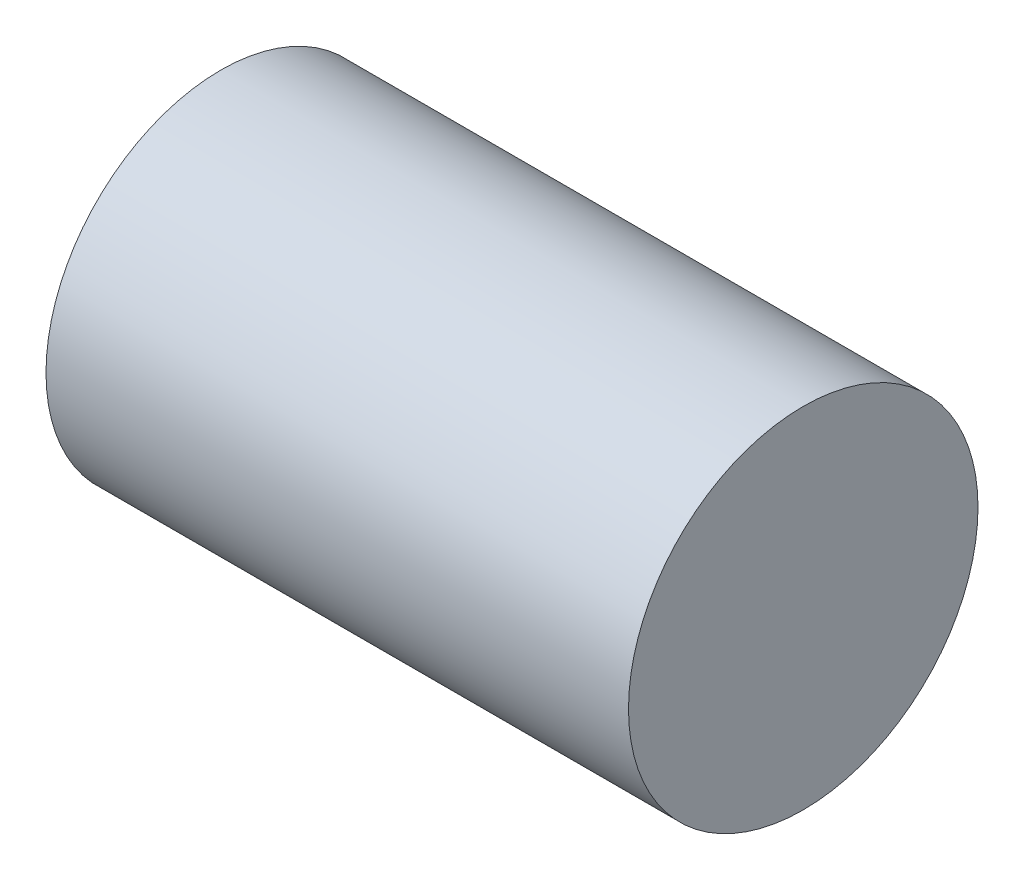
from build123d import *


with BuildPart() as part:
    # Sketch1 → Base-Revolve (revolve)
    with BuildSketch(Plane.XY):
        Polygon((0, 4), (0, 6), (20, 6), (20, 0), (17, 0), (17, 4), align=None)
    revolve(axis=Axis((-28, 0, 0), (1, 0, 0)))


solid = part.part
